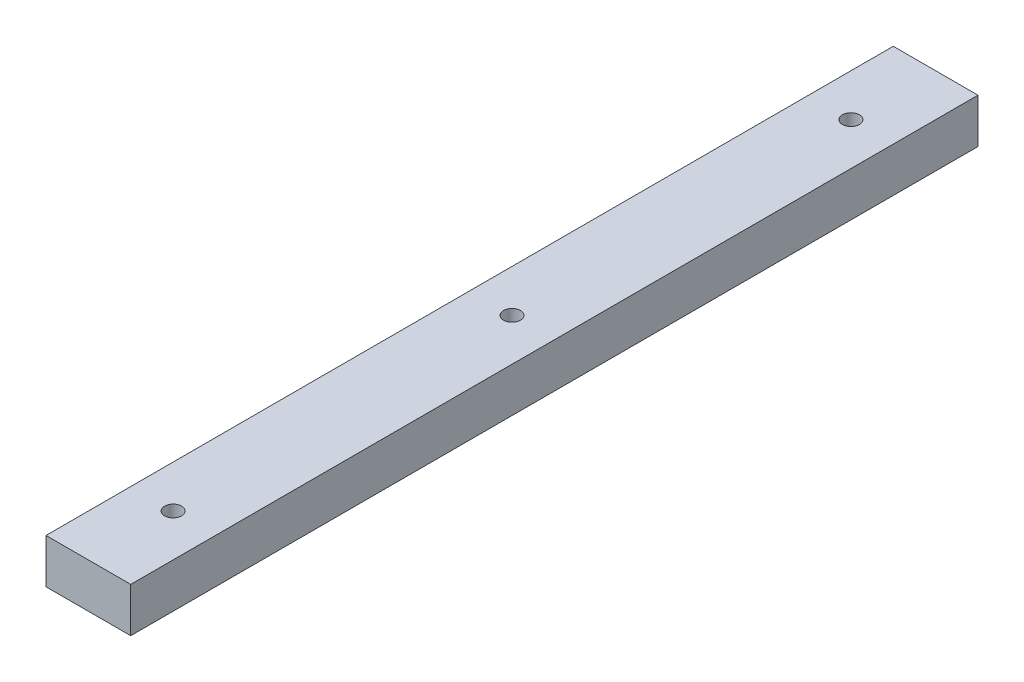
from build123d import *

# Parameters (mm, degrees)
SKETCH1_W           = 20
SKETCH1_H           = 200
SKETCH1_R           = 2
BOSS_EXTRUDE1_DEPTH = 10.5


with BuildPart() as part:
    # Sketch1 → Boss-Extrude1 (new body)
    with BuildSketch(Plane(origin=(0, 0, 0), x_dir=(1, 0, 0), z_dir=(0, 1, 0))):
        Rectangle(SKETCH1_W, SKETCH1_H)
        with Locations((0, 80)):
            Circle(SKETCH1_R, mode=Mode.SUBTRACT)
        Circle(SKETCH1_R, mode=Mode.SUBTRACT)
        with Locations((0, -80)):
            Circle(SKETCH1_R, mode=Mode.SUBTRACT)
    extrude(amount=BOSS_EXTRUDE1_DEPTH)


solid = part.part
